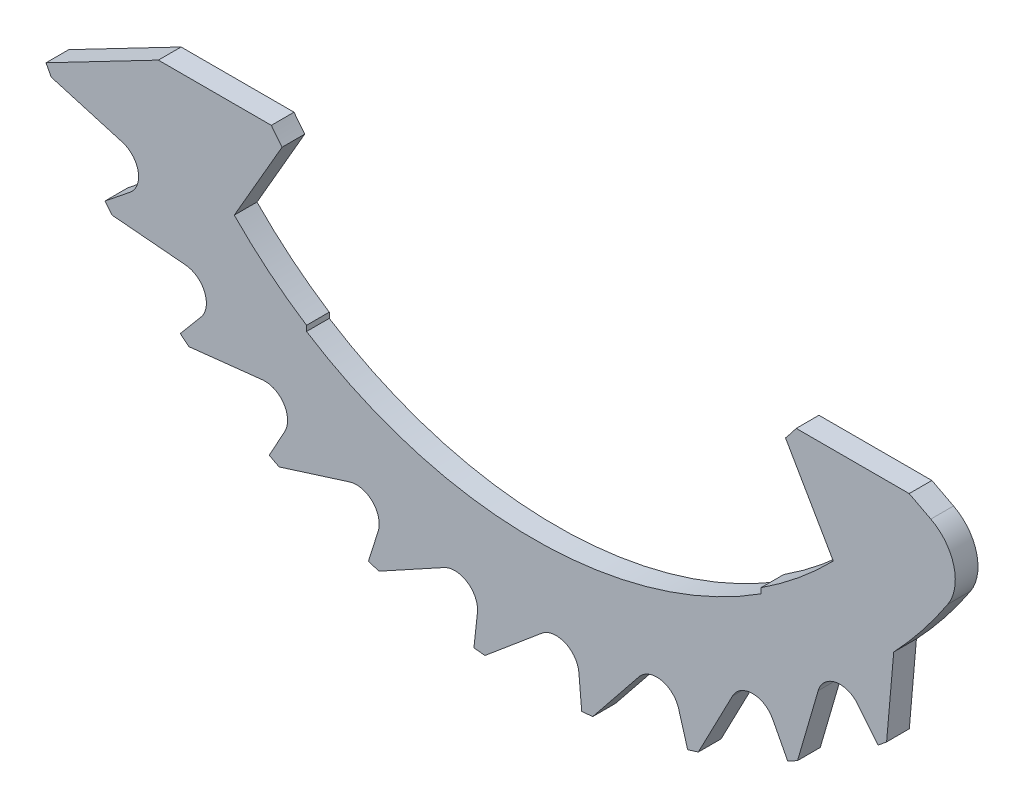
from build123d import *

# Parameters (mm, degrees)
BOSS_EXTRUDE1_DEPTH = 0.5
CUT_EXTRUDE1_DEPTH  = 0.5
CIRPATTERN1_COUNT   = 10
CIRPATTERN1_ANGLE   = 101.25
CUT_EXTRUDE3_START  = -0.5
CUT_EXTRUDE3_DEPTH  = 0.5
FILLET3_R           = 1


with BuildPart() as part:
    # Sketch1 → Boss-Extrude1 (new body)
    with BuildSketch(Plane.XY):
        with BuildLine():
            Line((-8.260223146, -4.3), (-10.732831081, -5.58715822))
            ThreePointArc((-10.732831081, -5.58715822), (0, -12.1), (10.732831081, -5.58715822))
            Line((10.732831081, -5.58715822), (8.260223146, -4.3))
            Line((8.260223146, -4.3), (5.774945887, -4.3))
            ThreePointArc((5.774945887, -4.3), (5.659072475, -4.451392897), (5.53923133, -4.5996648))
            Line((5.53923133, -4.5996648), (6.59, -6.419649523))
            ThreePointArc((6.59, -6.419649523), (5.831509763, -7.1157216), (5, -7.722693831))
            Line((5, -7.722693831), (5, -7.841555968))
            ThreePointArc((5, -7.841555968), (0, -9.3), (-5, -7.841555968))
            Line((-5, -7.841555968), (-5, -7.722693831))
            ThreePointArc((-5, -7.722693831), (-5.831509763, -7.1157216), (-6.59, -6.419649523))
            Line((-6.59, -6.419649523), (-5.53923133, -4.5996648))
            ThreePointArc((-5.53923133, -4.5996648), (-5.659072475, -4.451392897), (-5.774945887, -4.3))
            Line((-5.774945887, -4.3), (-8.260223146, -4.3))
        make_face()
    extrude(amount=BOSS_EXTRUDE1_DEPTH)

    # Sketch2 → Cut-Extrude1 (cut)
    with BuildSketch(Plane.XY.offset(0.5)):
        with BuildLine():
            Line((-10.617511084, -5.803314431), (-9.055174855, -6.258693914))
            ThreePointArc((-9.055174855, -6.258693914), (-8.704696722, -6.641173681), (-8.882127626, -7.128661083))
            Line((-8.882127626, -7.128661083), (-9.436602245, -7.573674013))
            ThreePointArc((-9.436602245, -7.573674013), (-10.066052286, -6.714506042), (-10.617511084, -5.803314431))
        make_face()
    cut_extrude1 = extrude(amount=-CUT_EXTRUDE1_DEPTH, mode=Mode.SUBTRACT)

    # CirPattern1: Cut-Extrude1 ×10 about axis
    cirpattern1_axis = Axis((0, 0, 0), (0, 0, 1))
    for i in range(1, CIRPATTERN1_COUNT):
        add(cut_extrude1.rotate(cirpattern1_axis, i * CIRPATTERN1_ANGLE / (CIRPATTERN1_COUNT - 1)), mode=Mode.SUBTRACT)

    # Sketch3 → Cut-Extrude3 (cut)
    with BuildSketch(Plane.XY.offset(0.5).offset(CUT_EXTRUDE3_START)):
        with BuildLine():
            Line((7.919995926, -7.488902759), (7.763179028, -9.281328104))
            ThreePointArc((7.763179028, -9.281328104), (9.430658528, -7.581073784), (10.732831081, -5.58715822))
            Line((10.732831081, -5.58715822), (9.668418082, -5.033059884))
            ThreePointArc((9.668418082, -5.033059884), (8.879519575, -6.321719079), (7.919995926, -7.488902759))
        make_face()
    extrude(amount=CUT_EXTRUDE3_DEPTH, mode=Mode.SUBTRACT)

    # Fillet3
    fillet3_edges = [part.edges().sort_by_distance(p)[0] for p in [
        (9.668418082, -5.033059884, 0.25),
    ]]
    fillet(fillet3_edges, radius=FILLET3_R)


solid = part.part
